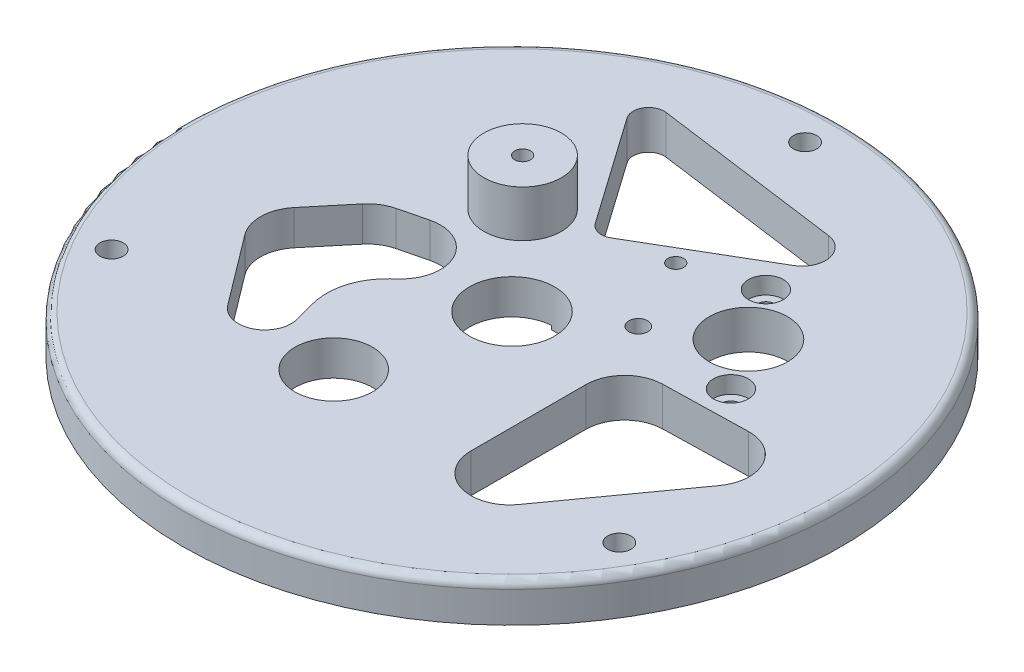
from build123d import *

# Parameters (mm, degrees)
SKETCH1_R                = 42.5
SKETCH1_R_2              = 5
BOSS_EXTRUDE1_DEPTH      = 5
SKETCH2_R                = 1.2
SKETCH2_R_2              = 1.225
SKETCH2_R_3              = 5.05
SKETCH2_R_4              = 1.015
CUT_EXTRUDE1_DEPTH       = 10
SKETCH5_R                = 5
SKETCH5_R_2              = 1.015
BOSS_EXTRUDE2_DEPTH      = 6
SKETCH9_R                = 2.357259082
BOSS_EXTRUDE4_DEPTH      = 1
FILLET1_R                = 1
SKETCH10_R               = 1.5
CUT_EXTRUDE3_DEPTH       = 2.2
CUT_EXTRUDE3_DEPTH_BACK  = 16
CUT_EXTRUDE6_DEPTH       = 0.5
CUT_EXTRUDE7_DEPTH       = 10
CUT_EXTRUDE8_DEPTH       = 10
CUT_EXTRUDE8_DEPTH_BACK  = 10
CUT_EXTRUDE9_DEPTH       = 10
CUT_EXTRUDE9_DEPTH_BACK  = 10
SKETCH17_R               = 5.5
CUT_EXTRUDE10_DEPTH      = 10
CUT_EXTRUDE10_DEPTH_BACK = 10
SKETCH18_R               = 2.25
CUT_EXTRUDE11_DEPTH      = 2.2


with BuildPart() as part:
    # Sketch1 → Boss-Extrude1 (new body)
    with BuildSketch(Plane(origin=(0, 0, 0), x_dir=(1, 0, 0), z_dir=(0, 1, 0))):
        Circle(SKETCH1_R)
        with Locations((-5.00907497, -17.981343775)):
            Circle(SKETCH1_R_2, mode=Mode.SUBTRACT)
    extrude(amount=BOSS_EXTRUDE1_DEPTH)

    # Sketch2 → Cut-Extrude1 (cut)
    with BuildSketch(Plane(origin=(0, 5, 0), x_dir=(1, 0, 0), z_dir=(0, 1, 0))):
        with Locations((22.761295372, 5.470231528)):
            Circle(SKETCH2_R)
        with Locations((13.931063063, 18.812907323)):
            Circle(SKETCH2_R)
        with Locations((9.801070346, 6.486384692)):
            Circle(SKETCH2_R_2)
        with Locations((18.346179218, 12.141569425)):
            Circle(SKETCH2_R_3)
        with Locations((5.141105692, 15.974131645)):
            Circle(SKETCH2_R_4)
    extrude(amount=-CUT_EXTRUDE1_DEPTH, mode=Mode.SUBTRACT)

    # Sketch5 → Boss-Extrude2 (add)
    with BuildSketch(Plane(origin=(0, 5, 0), x_dir=(1, 0, 0), z_dir=(0, 1, 0))):
        with Locations((-10.748331153, 12.120782872)):
            Circle(SKETCH5_R)
        with Locations((-10.748331153, 12.120782872)):
            Circle(SKETCH5_R_2, mode=Mode.SUBTRACT)
    extrude(amount=BOSS_EXTRUDE2_DEPTH)

    # Sketch9 → Boss-Extrude4 (add)
    with BuildSketch(Plane.XZ):
        with Locations((5.141105692, -15.974131645)):
            Circle(SKETCH9_R)
    extrude(amount=-BOSS_EXTRUDE4_DEPTH)

    # Fillet1
    fillet1_edges = [part.edges().sort_by_distance(p)[0] for p in [
        (-42.5, 5, 0),
    ]]
    fillet(fillet1_edges, radius=FILLET1_R)

    # Sketch10 → Cut-Extrude3 (cut, two sides)
    with BuildSketch(Plane(origin=(0, 5, 0), x_dir=(1, 0, 0), z_dir=(0, 1, 0))) as cut_extrude3_sk:
        with Locations((0, 37.8)):
            Circle(SKETCH10_R)
        with Locations((-32.735760263, -18.9)):
            Circle(SKETCH10_R)
        with Locations((32.735760263, -18.9)):
            Circle(SKETCH10_R)
    extrude(amount=CUT_EXTRUDE3_DEPTH, mode=Mode.SUBTRACT)
    extrude(cut_extrude3_sk.sketch, amount=-CUT_EXTRUDE3_DEPTH_BACK, mode=Mode.SUBTRACT)

    # Sketch12 → Cut-Extrude6 (cut)
    with BuildSketch(Plane.XZ):
        with BuildLine():
            Line((-18.74897508, 25.683138694), (-31.97397508, 2.776766764))
            ThreePointArc((-31.97397508, 2.776766764), (-32.473477192, -1.017328462), (-30.143848061, -4.053360255))
            Line((-30.143848061, -4.053360255), (-11.524301879, -14.803360255))
            ThreePointArc((-11.524301879, -14.803360255), (-7.730206654, -15.302862368), (-4.694174861, -12.973233236))
            Line((-4.694174861, -12.973233236), (8.530825139, 9.933138694))
            ThreePointArc((8.530825139, 9.933138694), (2.76592503, 31.448038804), (-18.74897508, 25.683138694))
        make_face()
    extrude(amount=-CUT_EXTRUDE6_DEPTH, mode=Mode.SUBTRACT)

    # Sketch13 → Cut-Extrude7 (cut)
    with BuildSketch(Plane(origin=(0, 5, 0), x_dir=(1, 0, 0), z_dir=(0, 1, 0))):
        with BuildLine():
            Line((32.816836472, -6.07169605), (21.984996749, -21.138640776))
            ThreePointArc((21.984996749, -21.138640776), (16.391033491, -22.978825985), (12.925236211, -18.21784334))
            Line((12.925236211, -18.21784334), (12.931687147, -3.407234286))
            ThreePointArc((12.931687147, -3.407234286), (14.35531099, 0.084802692), (17.813324255, 1.589186743))
            Line((17.813324255, 1.589186743), (28.638713042, 1.845522414))
            ThreePointArc((28.638713042, 1.845522414), (33.179093412, -0.819461796), (32.816836472, -6.07169605))
        make_face()
    extrude(amount=-CUT_EXTRUDE7_DEPTH, mode=Mode.SUBTRACT)

    # Sketch15 → Cut-Extrude8 (cut, two sides)
    with BuildSketch(Plane.XZ.offset(-0.5)) as cut_extrude8_sk:
        with BuildLine():
            Line((-4.454061063, -15.186961023), (-14.190064184, -29.028285448))
            ThreePointArc((-14.190064184, -29.028285448), (-14.263329759, -31.217660805), (-12.286203391, -32.160901823))
            Line((-12.286203391, -32.160901823), (11.926297184, -28.886712635))
            ThreePointArc((11.926297184, -28.886712635), (14.476623444, -26.492368994), (13.043930349, -23.301062679))
            Line((13.043930349, -23.301062679), (-1.808225202, -14.611372289))
            ThreePointArc((-1.808225202, -14.611372289), (-3.243361659, -14.383326468), (-4.454061063, -15.186961023))
        make_face()
    extrude(amount=CUT_EXTRUDE8_DEPTH, mode=Mode.SUBTRACT)
    extrude(cut_extrude8_sk.sketch, amount=-CUT_EXTRUDE8_DEPTH_BACK, mode=Mode.SUBTRACT)

    # Sketch16 → Cut-Extrude9 (cut, two sides)
    with BuildSketch(Plane.XZ.offset(-0.5)) as cut_extrude9_sk:
        with BuildLine():
            Line((-12.984156175, 14.705600426), (-13.719701132, 11.95882482))
            ThreePointArc((-13.719701132, 11.95882482), (-13.693758532, 7.802544191), (-11.54963643, 4.241914739))
            Line((-11.54963643, 4.241914739), (-10.842839117, 3.568938111))
            ThreePointArc((-10.842839117, 3.568938111), (-9.907482144, -2.457917187), (-15.493944375, -4.905225341))
            Line((-15.493944375, -4.905225341), (-19.004093622, -4.034917019))
            ThreePointArc((-19.004093622, -4.034917019), (-20.457115896, -3.417911536), (-21.645362284, -2.3786618))
            Line((-21.645362284, -2.3786618), (-25.653320737, 2.441392154))
            ThreePointArc((-25.653320737, 2.441392154), (-26.807383132, 5.519886283), (-25.80025353, 8.649531003))
            Line((-25.80025353, 8.649531003), (-19.012059198, 17.647148968))
            ThreePointArc((-19.012059198, 17.647148968), (-14.786139745, 18.659973084), (-12.984156175, 14.705600426))
        make_face()
    extrude(amount=CUT_EXTRUDE9_DEPTH, mode=Mode.SUBTRACT)
    extrude(cut_extrude9_sk.sketch, amount=-CUT_EXTRUDE9_DEPTH_BACK, mode=Mode.SUBTRACT)

    # Sketch17 → Cut-Extrude10 (cut, two sides)
    with BuildSketch(Plane.XZ.offset(-0.5)) as cut_extrude10_sk:
        Circle(SKETCH17_R)
    extrude(amount=CUT_EXTRUDE10_DEPTH, mode=Mode.SUBTRACT)
    extrude(cut_extrude10_sk.sketch, amount=-CUT_EXTRUDE10_DEPTH_BACK, mode=Mode.SUBTRACT)

    # Sketch18 → Cut-Extrude11 (cut)
    with BuildSketch(Plane(origin=(0, 5, 0), x_dir=(1, 0, 0), z_dir=(0, 1, 0))):
        with Locations((13.931063063, 18.812907323)):
            Circle(SKETCH18_R)
        with Locations((22.761295372, 5.470231528)):
            Circle(SKETCH18_R)
    extrude(amount=-CUT_EXTRUDE11_DEPTH, mode=Mode.SUBTRACT)


solid = part.part
